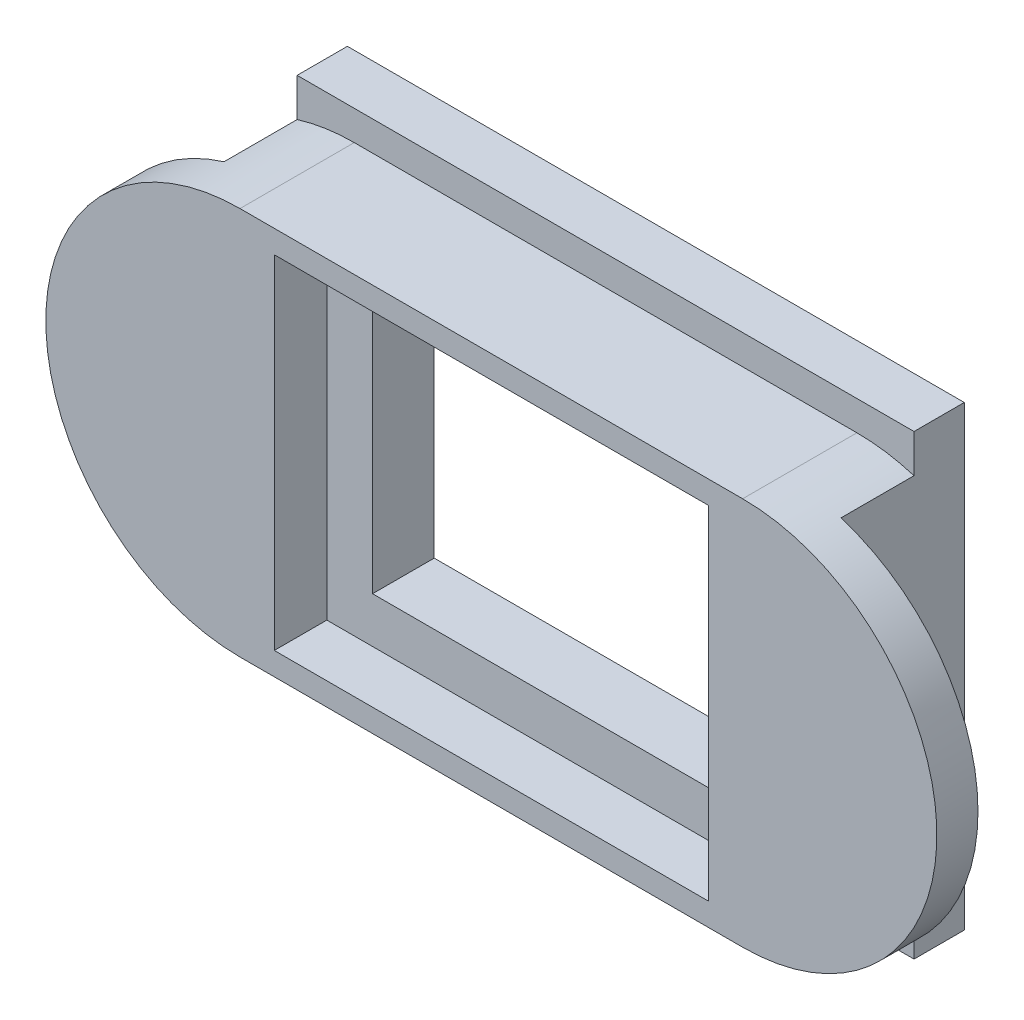
from build123d import *

# Parameters (mm, degrees)
SKETCH_1_W           = 15
SKETCH_1_H           = 11
EXTRUDE_1_DEPTH      = 5
SKETCH_2_W           = 19
SKETCH_2_H           = 15
CUT_EXTRUDE_1_DEPTH  = 2.3
SKETCH_3_OUTSIDE_W   = 49.568
SKETCH_3_OUTSIDE_H   = 27.568
SKETCH_3_OUTSIDE_W_2 = 27
SKETCH_3_OUTSIDE_H_2 = 17
CUT_EXTRUDE_2_DEPTH  = 3.2
SKETCH_4_W           = 27
SKETCH_4_H           = 20
EXTRUDE_2_DEPTH      = 2.2
SKETCH_5_W           = 15
SKETCH_5_H           = 11
CUT_EXTRUDE_3_DEPTH  = 3.2
CUT_EXTRUDE_3_TAPER  = -57


with BuildPart() as part:
    # Эскиз1 → Бобышка-Вытянуть1 (new body)
    with BuildSketch(Plane.XY):
        with BuildLine():
            Line((-11, 8.5), (11, 8.5))
            ThreePointArc((11, 8.5), (19.5, 0), (11, -8.5))
            Line((11, -8.5), (-11, -8.5))
            ThreePointArc((-11, -8.5), (-19.5, 0), (-11, 8.5))
        make_face()
        Rectangle(SKETCH_1_W, SKETCH_1_H, mode=Mode.SUBTRACT)
    extrude(amount=EXTRUDE_1_DEPTH)

    # Эскиз2 → Вырез-Вытянуть1 (cut)
    with BuildSketch(Plane.XY.offset(5)):
        Rectangle(SKETCH_2_W, SKETCH_2_H)
    extrude(amount=-CUT_EXTRUDE_1_DEPTH, mode=Mode.SUBTRACT)

    # Эскиз3 outside → Вырез-Вытянуть2 (cut)
    with BuildSketch(Plane(origin=(0, 0, 0), x_dir=(-1, 0, 0), z_dir=(0, 0, -1))):
        Rectangle(SKETCH_3_OUTSIDE_W, SKETCH_3_OUTSIDE_H)
        Rectangle(SKETCH_3_OUTSIDE_W_2, SKETCH_3_OUTSIDE_H_2, mode=Mode.SUBTRACT)
    extrude(amount=-CUT_EXTRUDE_2_DEPTH, mode=Mode.SUBTRACT)

    # Эскиз4 → Бобышка-Вытянуть2 (add)
    with BuildSketch(Plane(origin=(0, 0, 0), x_dir=(-1, 0, 0), z_dir=(0, 0, -1))):
        with Locations((0, -0.2)):
            Rectangle(SKETCH_4_W, SKETCH_4_H)
    extrude(amount=EXTRUDE_2_DEPTH)

    # Эскиз5 → Вырез-Вытянуть3 (cut, through all)
    with BuildSketch(Plane.XY):
        Rectangle(SKETCH_5_W, SKETCH_5_H)
    extrude(amount=-CUT_EXTRUDE_3_DEPTH, taper=CUT_EXTRUDE_3_TAPER, mode=Mode.SUBTRACT)


solid = part.part
